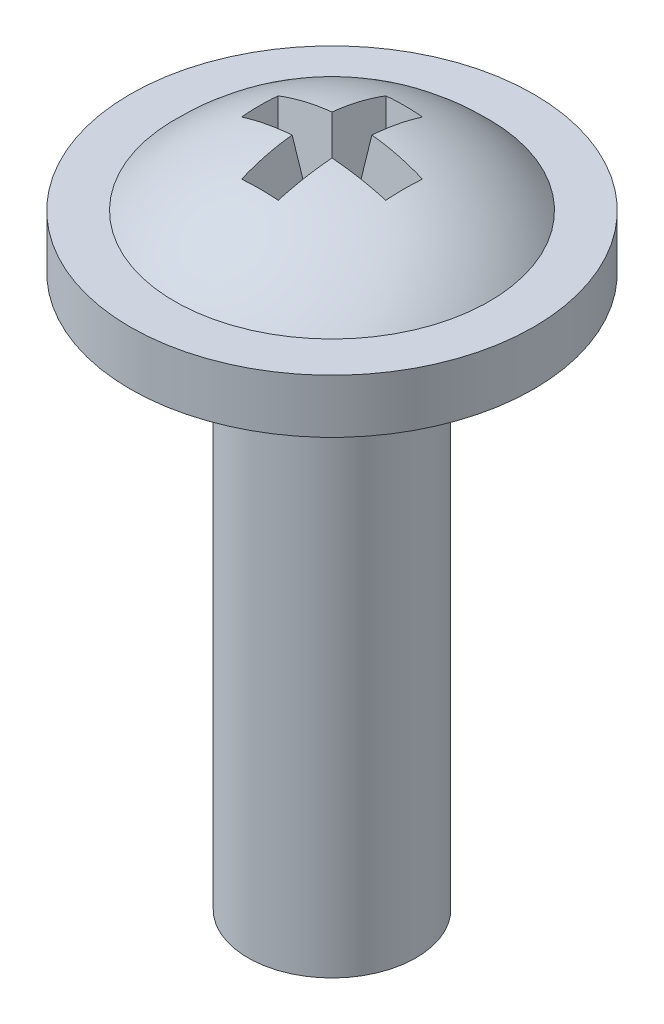
from build123d import *

# Parameters (mm, degrees)
CUT_EXTRUDE1_DEPTH = 2.032
CUT_EXTRUDE1_TAPER = 8


with BuildPart() as part:
    # Sketch1 → Base-Revolve (revolve)
    with BuildSketch(Plane.XY):
        with BuildLine():
            Line((0, 0), (1.5875, 0))
            Line((1.5875, 0), (1.5875, 10.414))
            Line((1.5875, 10.414), (3.81, 10.414))
            Line((3.81, 10.414), (3.81, 11.43))
            Line((3.81, 11.43), (2.9718, 11.43))
            ThreePointArc((2.9718, 11.43), (1.615897215, 12.369193484), (0, 12.7))
            Line((0, 12.7), (0, 0))
        make_face()
    revolve(axis=Axis((0, 0, 0), (0, 1, 0)))

    # Sketch2 → Cut-Extrude1 (cut)
    with BuildSketch(Plane(origin=(0, 12.7, 0), x_dir=(-1, 0, 0), z_dir=(0, 1, 0))):
        Polygon((0.381, 1.397), (-0.381, 1.397), (-0.381, 0.381), (-1.397, 0.381), (-1.397, -0.381), (-0.381, -0.381), (-0.381, -1.397), (0.381, -1.397), (0.381, -0.381), (1.397, -0.381), (1.397, 0.381), (0.381, 0.381), align=None)
    extrude(amount=-CUT_EXTRUDE1_DEPTH, taper=CUT_EXTRUDE1_TAPER, mode=Mode.SUBTRACT)


solid = part.part
